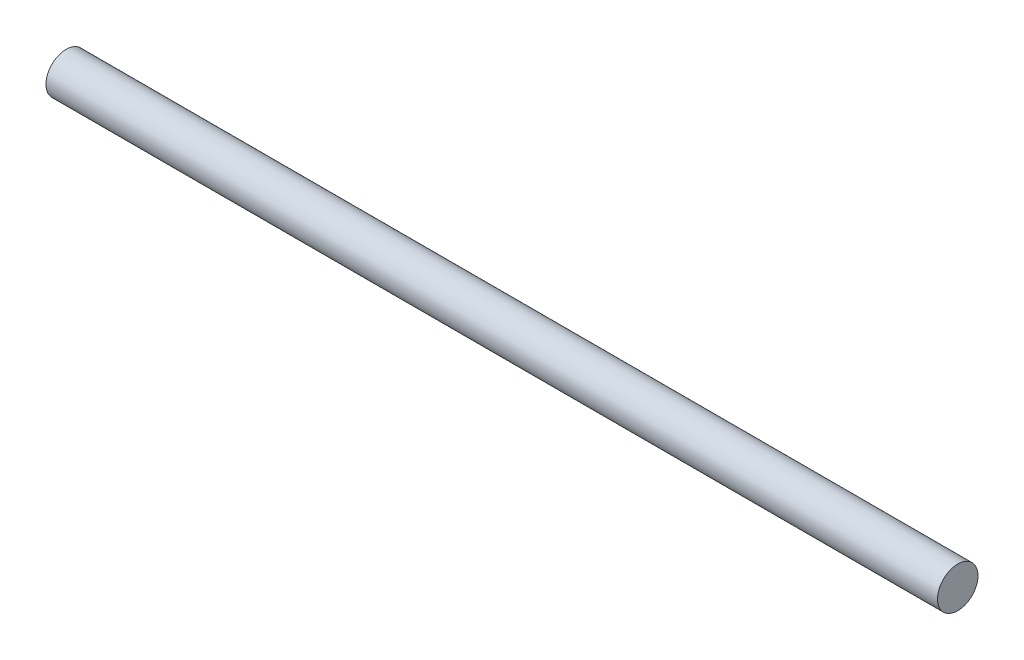
from build123d import *

# Parameters (mm, degrees)
SKETCH1_R           = 6.35
BOSS_EXTRUDE1_DEPTH = 139.7


with BuildPart() as part:
    # Sketch1 → Boss-Extrude1 (new body, symmetric)
    with BuildSketch(Plane(origin=(0, 0, 0), x_dir=(0, 0, -1), z_dir=(1, 0, 0))):
        Circle(SKETCH1_R)
    extrude(amount=BOSS_EXTRUDE1_DEPTH, both=True)


solid = part.part
